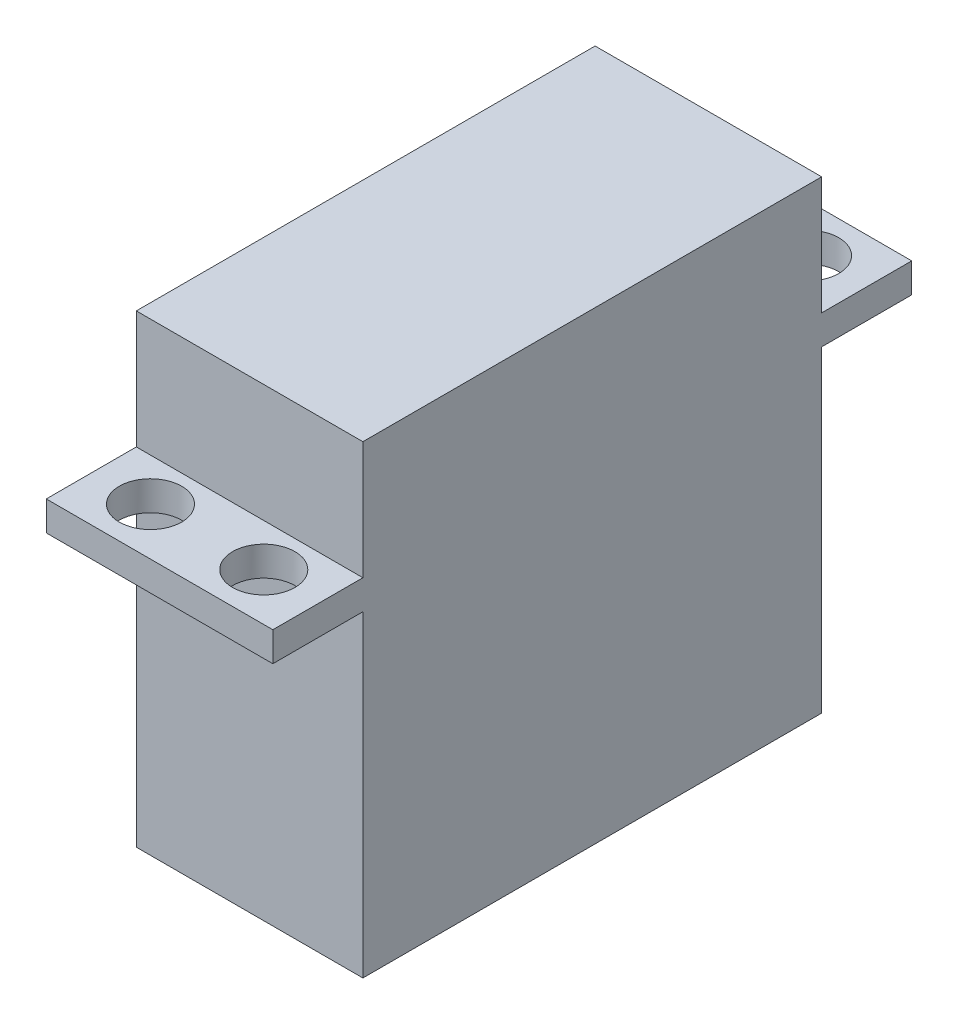
from build123d import *

# Parameters (mm, degrees)
SKETCH2_W            = 20
SKETCH2_H            = 40.5
BOSS_EXTRUDE1_DEPTH  = 41
SKETCH3_W            = 20
SKETCH3_H            = 56.4
BOSS_EXTRUDE2_DEPTH  = 2.6
M5_CLEARANCE_HOLE1_D = 5.5


with BuildPart() as part:
    # Sketch2 → Boss-Extrude1 (new body)
    with BuildSketch(Plane(origin=(0, 0, 0), x_dir=(1, 0, 0), z_dir=(0, 1, 0))):
        Rectangle(SKETCH2_W, SKETCH2_H)
    extrude(amount=BOSS_EXTRUDE1_DEPTH)

    # Sketch3 → Boss-Extrude2 (add)
    with BuildSketch(Plane(origin=(0, 28, 0), x_dir=(1, 0, 0), z_dir=(0, 1, 0))):
        Rectangle(SKETCH3_W, SKETCH3_H)
    extrude(amount=BOSS_EXTRUDE2_DEPTH)

    # M5 Clearance Hole1 (through all)
    with Locations(Plane(origin=(0, 30.6, 0), x_dir=(1, 0, 0), z_dir=(0, 1, 0))):
        with Locations((-5, 24), (5, 24), (5, -24), (-5, -24)):
            Hole(M5_CLEARANCE_HOLE1_D / 2)


solid = part.part
